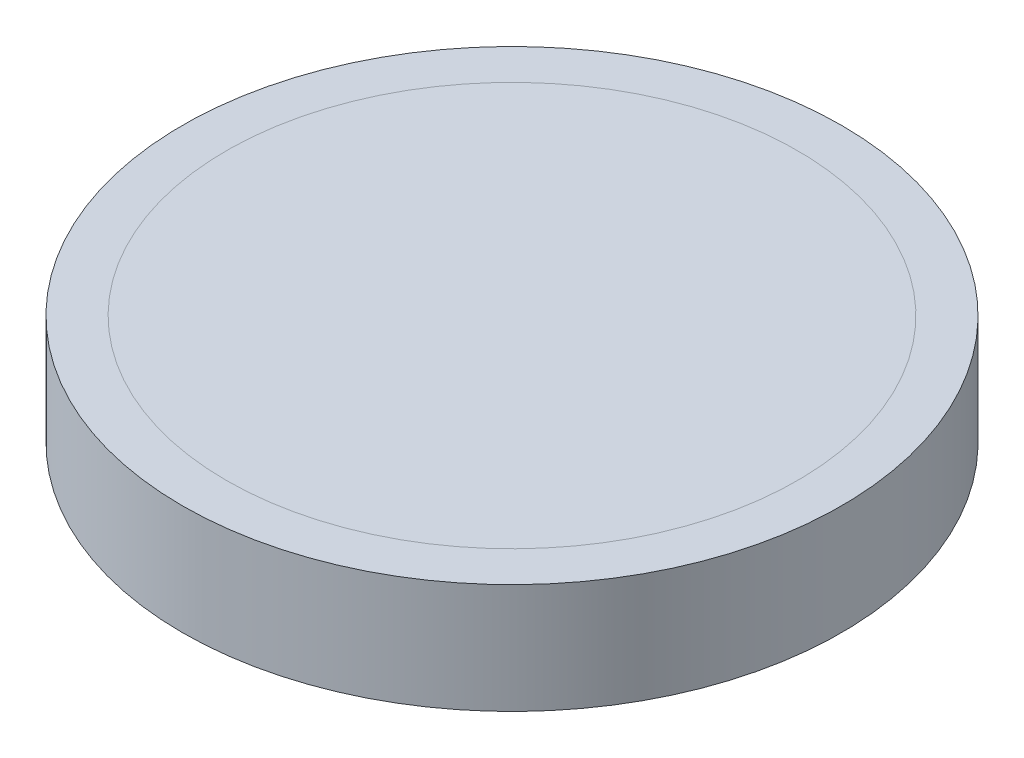
from build123d import *

# Parameters (mm, degrees)
SKETCH1_R           = 19.05
BOSS_EXTRUDE1_DEPTH = 6.35
SHELL1_T            = -2.54
BOSS_EXTRUDE3_REACH = 29.679
SKETCH35_R          = 44.45
CUT_EXTRUDE4_DEPTH  = 1.27


with BuildPart() as part:
    # Sketch1 → Boss-Extrude1 (new body)
    with BuildSketch(Plane(origin=(0, 0, 0), x_dir=(1, 0, 0), z_dir=(0, 1, 0))):
        with Locations(Location((0, 0, 0), (0, 0, 270))):
            Circle(SKETCH1_R)
    extrude(amount=BOSS_EXTRUDE1_DEPTH)

    # Shell1
    shell1_openings = [part.faces().sort_by_distance(p)[0] for p in [
        (0, 6.35, 0),
    ]]
    offset(amount=SHELL1_T, openings=shell1_openings, kind=Kind.INTERSECTION)


with BuildPart() as body_2:

    # Sketch35 → Boss-Extrude3 (new, up to next)
    with BuildSketch(Plane(origin=(0, 6.35, 0), x_dir=(1, 0, 0), z_dir=(0, 1, 0)), mode=Mode.PRIVATE) as boss_extrude3_sk1:
        Circle(SKETCH35_R)
    boss_extrude3_tool1 = extrude(boss_extrude3_sk1.sketch, amount=-BOSS_EXTRUDE3_REACH, mode=Mode.PRIVATE) - part.part
    add(boss_extrude3_tool1.solids().sort_by_distance((0, 6.35, 0))[0])


with BuildPart() as part_1:
    add(part.part)

    # Sketch36 → Cut-Extrude4 (cut)
    with BuildSketch(Plane.XZ):
        Polygon((-3.264836953, 1.543049673), (-2.979901056, 1.543049673), (-2.979901056, 0.333980162), (-1.656348371, 1.543049673), (-1.249933107, 1.543049673), (-2.810084349, 0.118370186), (-1.127817722, -1.631950327), (-1.507520246, -1.631950327), (-2.979901056, -0.09978386), (-2.979901056, -1.631950327), (-3.264836953, -1.631950327), align=None)
        Polygon((-0.659708748, 1.543049673), (-0.37477285, 1.543049673), (-0.37477285, -1.306309301), (0.846380996, -1.306309301), (0.846380996, -1.631950327), (-0.659708748, -1.631950327), align=None)
        Polygon((1.172022021, 1.543049673), (1.466498183, 1.543049673), (2.087887406, -0.785410864), (3.01202102, 1.543049673), (3.053362166, 1.543049673), (3.960323303, -0.769510423), (4.584892614, 1.543049673), (4.876188688, 1.543049673), (4.02010896, -1.631950327), (3.979403832, -1.631950327), (3.024105355, 0.796364978), (2.05735856, -1.631950327), (2.016653432, -1.631950327), align=None)
        Polygon((5.28323997, 1.217408648), (5.28323997, 1.543049673), (6.952150226, 1.543049673), (5.620329313, -1.306309301), (6.911445098, -1.306309301), (6.911445098, -1.631950327), (5.161124585, -1.631950327), (6.492945499, 1.217408648), align=None)
    extrude(amount=-CUT_EXTRUDE4_DEPTH, mode=Mode.SUBTRACT)


solid = Compound([body_2.part, part_1.part])
